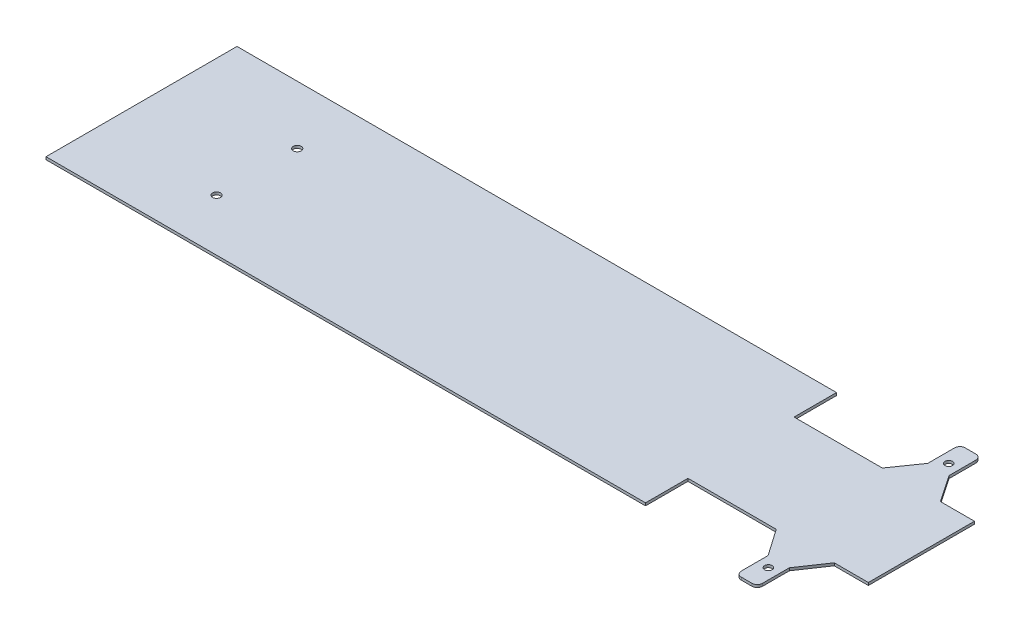
from build123d import *

# Parameters (mm, degrees)
SKETCH1_R           = 7
BOSS_EXTRUDE1_DEPTH = 5
SKETCH2_R           = 7.5
CUT_EXTRUDE1_DEPTH  = 10


with BuildPart() as part:
    # Sketch1 → Boss-Extrude1 (new body)
    with BuildSketch(Plane(origin=(0, 0, 0), x_dir=(1, 0, 0), z_dir=(0, 1, 0))):
        with BuildLine():
            Line((-415.542365302, 422.631578947), (-351.296475424, 422.631578947))
            Line((-351.296475424, 422.631578947), (-351.296475424, 222.631578947))
            Line((-351.296475424, 222.631578947), (-415.542365302, 222.631578947))
            Line((-415.542365302, 222.631578947), (-449.708642176, 172.131578947))
            Line((-449.708642176, 172.131578947), (-449.708642176, 121.631578947))
            ThreePointArc((-449.708642176, 121.631578947), (-452.637574364, 114.560511136), (-459.708642176, 111.631578947))
            Line((-459.708642176, 111.631578947), (-479.708642176, 111.631578947))
            ThreePointArc((-479.708642176, 111.631578947), (-486.779709988, 114.560511136), (-489.708642176, 121.631578947))
            Line((-489.708642176, 121.631578947), (-489.708642176, 172.131578947))
            Line((-489.708642176, 172.131578947), (-524.868977384, 222.631578947))
            Line((-524.868977384, 222.631578947), (-691.296475424, 222.631578947))
            Line((-691.296475424, 222.631578947), (-691.296475424, 142.631578947))
            Line((-691.296475424, 142.631578947), (-1821.296475424, 142.631578947))
            Line((-1821.296475424, 142.631578947), (-1821.296475424, 502.631578947))
            Line((-1821.296475424, 502.631578947), (-691.296475424, 502.631578947))
            Line((-691.296475424, 502.631578947), (-691.296475424, 422.631578947))
            Line((-691.296475424, 422.631578947), (-524.868977384, 422.631578947))
            Line((-524.868977384, 422.631578947), (-489.708642176, 473.131578947))
            Line((-489.708642176, 473.131578947), (-489.708642176, 523.631578947))
            ThreePointArc((-489.708642176, 523.631578947), (-486.779709988, 530.702646759), (-479.708642176, 533.631578947))
            Line((-479.708642176, 533.631578947), (-459.708642176, 533.631578947))
            ThreePointArc((-459.708642176, 533.631578947), (-452.637574364, 530.702646759), (-449.708642176, 523.631578947))
            Line((-449.708642176, 523.631578947), (-449.708642176, 473.131578947))
            Line((-449.708642176, 473.131578947), (-415.542365302, 422.631578947))
        make_face()
        with Locations((-469.708642176, 492.631578947)):
            Circle(SKETCH1_R, mode=Mode.SUBTRACT)
        with Locations((-469.708642176, 152.631578947)):
            Circle(SKETCH1_R, mode=Mode.SUBTRACT)
    extrude(amount=BOSS_EXTRUDE1_DEPTH)

    # Sketch2 → Cut-Extrude1 (cut)
    with BuildSketch(Plane(origin=(0, 5, 0), x_dir=(1, 0, 0), z_dir=(0, 1, 0))):
        with Locations((-1597.770206395, 392.549644623)):
            Circle(SKETCH2_R)
        with Locations((-1597.770206395, 240.60770245)):
            Circle(SKETCH2_R)
    extrude(amount=-CUT_EXTRUDE1_DEPTH, mode=Mode.SUBTRACT)


solid = part.part
